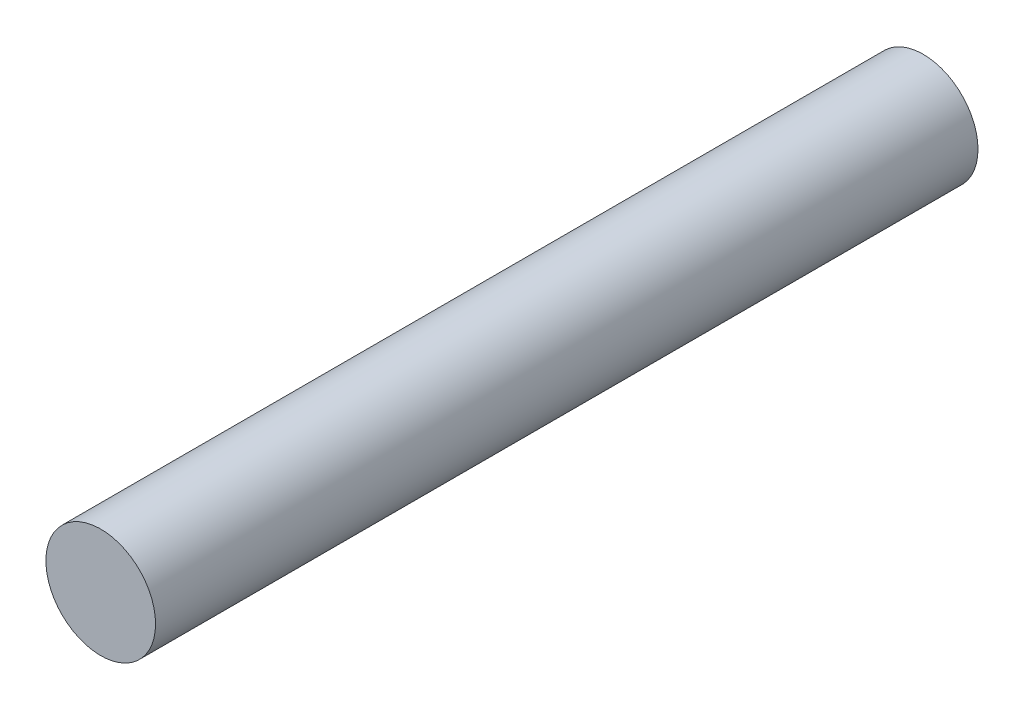
from build123d import *

# Parameters (mm, degrees)
SKETCH_1_R      = 4
EXTRUDE_1_DEPTH = 60


with BuildPart() as part:
    # 草图1 → 凸台-拉伸1 (new body)
    with BuildSketch(Plane.XY):
        Circle(SKETCH_1_R)
    extrude(amount=EXTRUDE_1_DEPTH)


solid = part.part
